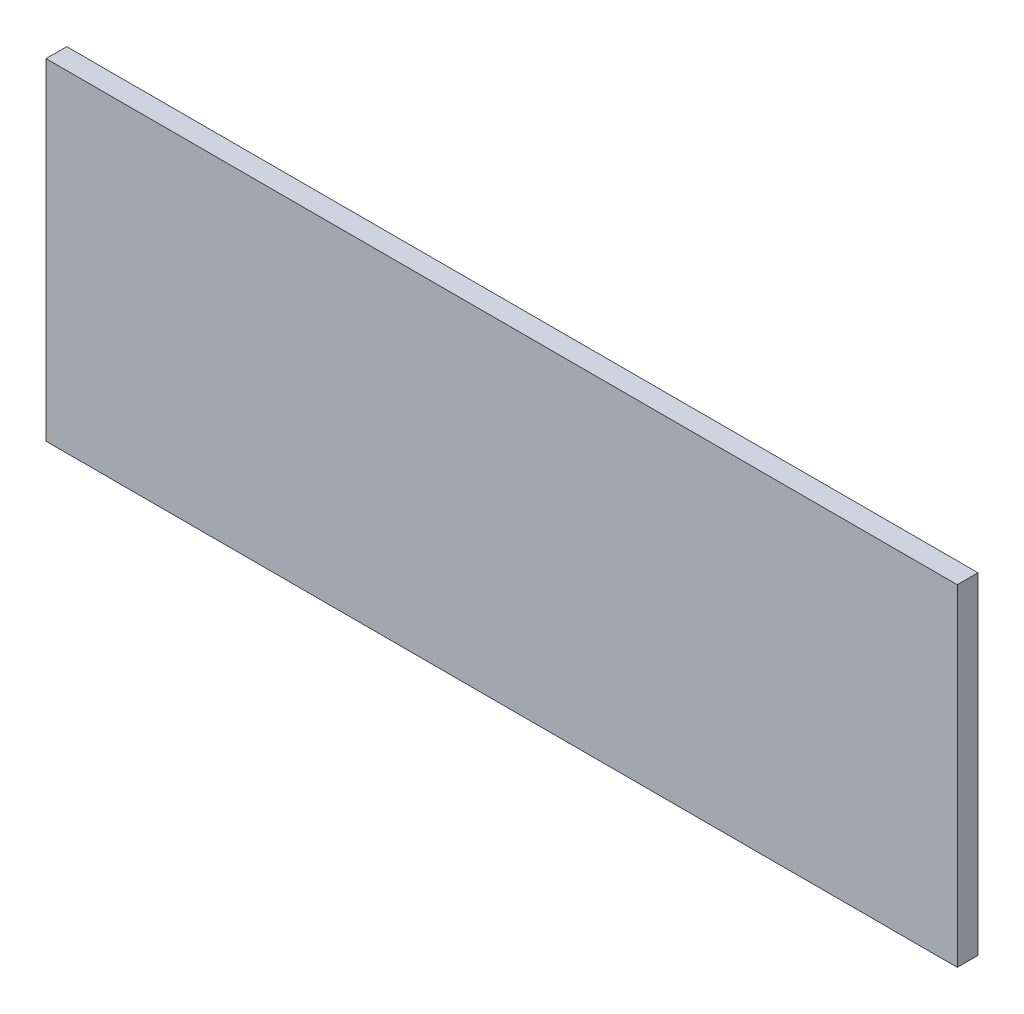
from build123d import *

# Parameters (mm, degrees)
SKETCH1_W           = 139.7
SKETCH1_H           = 50.8
BOSS_EXTRUDE1_DEPTH = 1.5875


with BuildPart() as part:
    # Sketch1 → Boss-Extrude1 (new body, symmetric)
    with BuildSketch(Plane.XY):
        Rectangle(SKETCH1_W, SKETCH1_H)
    extrude(amount=BOSS_EXTRUDE1_DEPTH, both=True)


solid = part.part
